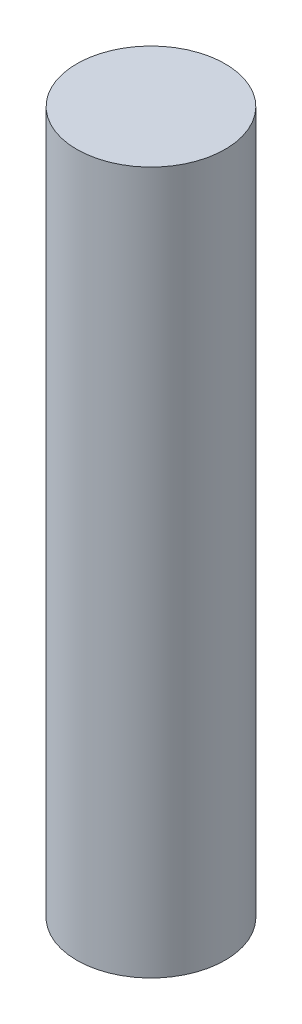
from build123d import *

# Parameters (mm, degrees)
SKETCH1_R           = 32.1945
BOSS_EXTRUDE1_DEPTH = 304.8


with BuildPart() as part:
    # Sketch1 → Boss-Extrude1 (new body)
    with BuildSketch(Plane(origin=(0, 0, 0), x_dir=(1, 0, 0), z_dir=(0, 1, 0))):
        Circle(SKETCH1_R)
    extrude(amount=BOSS_EXTRUDE1_DEPTH)


solid = part.part
